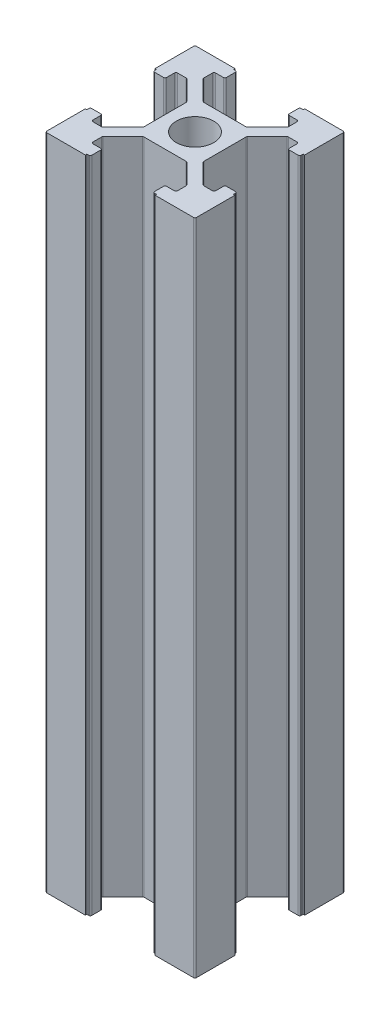
from build123d import *

# Parameters (mm, degrees)
SKETCH1_R           = 2.5
BOSS_EXTRUDE1_DEPTH = 88


with BuildPart() as part:
    # Sketch1 → Boss-Extrude1 (new body)
    with BuildSketch(Plane(origin=(0, 0, 0), x_dir=(1, 0, 0), z_dir=(0, 1, 0))):
        with BuildLine():
            Line((-10, 4.65), (-9.8, 4.65))
            Line((-9.8, 4.65), (-9.8, 4.4))
            ThreePointArc((-9.8, 4.4), (-9.741421356, 4.258578644), (-9.6, 4.2))
            Line((-9.6, 4.2), (-8.4, 4.2))
            ThreePointArc((-8.4, 4.2), (-8.258578644, 4.258578644), (-8.2, 4.4))
            Line((-8.2, 4.4), (-8.2, 5.45))
            ThreePointArc((-8.2, 5.45), (-8.141421356, 5.591421356), (-8, 5.65))
            Line((-8, 5.65), (-6.832842712, 5.65))
            ThreePointArc((-6.832842712, 5.65), (-6.756306026, 5.634775907), (-6.691421356, 5.591421356))
            Line((-6.691421356, 5.591421356), (-4.058578644, 2.958578644))
            ThreePointArc((-4.058578644, 2.958578644), (-4.015224093, 2.893693974), (-4, 2.817157288))
            Line((-4, 2.817157288), (-4, -2.817157288))
            ThreePointArc((-4, -2.817157288), (-4.015224093, -2.893693974), (-4.058578644, -2.958578644))
            Line((-4.058578644, -2.958578644), (-6.691421356, -5.591421356))
            ThreePointArc((-6.691421356, -5.591421356), (-6.756306026, -5.634775907), (-6.832842712, -5.65))
            Line((-6.832842712, -5.65), (-8, -5.65))
            ThreePointArc((-8, -5.65), (-8.141421356, -5.591421356), (-8.2, -5.45))
            Line((-8.2, -5.45), (-8.2, -4.4))
            ThreePointArc((-8.2, -4.4), (-8.258578644, -4.258578644), (-8.4, -4.2))
            Line((-8.4, -4.2), (-9.6, -4.2))
            ThreePointArc((-9.6, -4.2), (-9.741421356, -4.258578644), (-9.8, -4.4))
            Line((-9.8, -4.4), (-9.8, -4.65))
            Line((-9.8, -4.65), (-10, -4.65))
            Line((-10, -4.65), (-10, -9.8))
            ThreePointArc((-10, -9.8), (-9.941421356, -9.941421356), (-9.8, -10))
            Line((-9.8, -10), (-4.65, -10))
            Line((-4.65, -10), (-4.65, -9.8))
            Line((-4.65, -9.8), (-4.4, -9.8))
            ThreePointArc((-4.4, -9.8), (-4.258578644, -9.741421356), (-4.2, -9.6))
            Line((-4.2, -9.6), (-4.2, -8.4))
            ThreePointArc((-4.2, -8.4), (-4.258578644, -8.258578644), (-4.4, -8.2))
            Line((-4.4, -8.2), (-5.45, -8.2))
            ThreePointArc((-5.45, -8.2), (-5.591421356, -8.141421356), (-5.65, -8))
            Line((-5.65, -8), (-5.65, -6.832842712))
            ThreePointArc((-5.65, -6.832842712), (-5.634775907, -6.756306026), (-5.591421356, -6.691421356))
            Line((-5.591421356, -6.691421356), (-2.958578644, -4.058578644))
            ThreePointArc((-2.958578644, -4.058578644), (-2.893693974, -4.015224093), (-2.817157288, -4))
            Line((-2.817157288, -4), (2.817157288, -4))
            ThreePointArc((2.817157288, -4), (2.893693974, -4.015224093), (2.958578644, -4.058578644))
            Line((2.958578644, -4.058578644), (5.591421356, -6.691421356))
            ThreePointArc((5.591421356, -6.691421356), (5.634775907, -6.756306026), (5.65, -6.832842712))
            Line((5.65, -6.832842712), (5.65, -8))
            ThreePointArc((5.65, -8), (5.591421356, -8.141421356), (5.45, -8.2))
            Line((5.45, -8.2), (4.4, -8.2))
            ThreePointArc((4.4, -8.2), (4.258578644, -8.258578644), (4.2, -8.4))
            Line((4.2, -8.4), (4.2, -9.6))
            ThreePointArc((4.2, -9.6), (4.258578644, -9.741421356), (4.4, -9.8))
            Line((4.4, -9.8), (4.65, -9.8))
            Line((4.65, -9.8), (4.65, -10))
            Line((4.65, -10), (9.8, -10))
            ThreePointArc((9.8, -10), (9.941421356, -9.941421356), (10, -9.8))
            Line((10, -9.8), (10, -4.65))
            Line((10, -4.65), (9.8, -4.65))
            Line((9.8, -4.65), (9.8, -4.4))
            ThreePointArc((9.8, -4.4), (9.741421356, -4.258578644), (9.6, -4.2))
            Line((9.6, -4.2), (8.4, -4.2))
            ThreePointArc((8.4, -4.2), (8.258578644, -4.258578644), (8.2, -4.4))
            Line((8.2, -4.4), (8.2, -5.45))
            ThreePointArc((8.2, -5.45), (8.141421356, -5.591421356), (8, -5.65))
            Line((8, -5.65), (6.832842712, -5.65))
            ThreePointArc((6.832842712, -5.65), (6.756306026, -5.634775907), (6.691421356, -5.591421356))
            Line((6.691421356, -5.591421356), (4.058578644, -2.958578644))
            ThreePointArc((4.058578644, -2.958578644), (4.015224093, -2.893693974), (4, -2.817157288))
            Line((4, -2.817157288), (4, 2.817157288))
            ThreePointArc((4, 2.817157288), (4.015224093, 2.893693974), (4.058578644, 2.958578644))
            Line((4.058578644, 2.958578644), (6.691421356, 5.591421356))
            ThreePointArc((6.691421356, 5.591421356), (6.756306026, 5.634775907), (6.832842712, 5.65))
            Line((6.832842712, 5.65), (8, 5.65))
            ThreePointArc((8, 5.65), (8.141421356, 5.591421356), (8.2, 5.45))
            Line((8.2, 5.45), (8.2, 4.4))
            ThreePointArc((8.2, 4.4), (8.258578644, 4.258578644), (8.4, 4.2))
            Line((8.4, 4.2), (9.6, 4.2))
            ThreePointArc((9.6, 4.2), (9.741421356, 4.258578644), (9.8, 4.4))
            Line((9.8, 4.4), (9.8, 4.65))
            Line((9.8, 4.65), (10, 4.65))
            Line((10, 4.65), (10, 9.8))
            ThreePointArc((10, 9.8), (9.941421356, 9.941421356), (9.8, 10))
            Line((9.8, 10), (4.65, 10))
            Line((4.65, 10), (4.65, 9.8))
            Line((4.65, 9.8), (4.4, 9.8))
            ThreePointArc((4.4, 9.8), (4.258578644, 9.741421356), (4.2, 9.6))
            Line((4.2, 9.6), (4.2, 8.4))
            ThreePointArc((4.2, 8.4), (4.258578644, 8.258578644), (4.4, 8.2))
            Line((4.4, 8.2), (5.45, 8.2))
            ThreePointArc((5.45, 8.2), (5.591421356, 8.141421356), (5.65, 8))
            Line((5.65, 8), (5.65, 6.832842712))
            ThreePointArc((5.65, 6.832842712), (5.634775907, 6.756306026), (5.591421356, 6.691421356))
            Line((5.591421356, 6.691421356), (2.958578644, 4.058578644))
            ThreePointArc((2.958578644, 4.058578644), (2.893693974, 4.015224093), (2.817157288, 4))
            Line((2.817157288, 4), (-2.817157288, 4))
            ThreePointArc((-2.817157288, 4), (-2.893693974, 4.015224093), (-2.958578644, 4.058578644))
            Line((-2.958578644, 4.058578644), (-5.591421356, 6.691421356))
            ThreePointArc((-5.591421356, 6.691421356), (-5.634775907, 6.756306026), (-5.65, 6.832842712))
            Line((-5.65, 6.832842712), (-5.65, 8))
            ThreePointArc((-5.65, 8), (-5.591421356, 8.141421356), (-5.45, 8.2))
            Line((-5.45, 8.2), (-4.4, 8.2))
            ThreePointArc((-4.4, 8.2), (-4.258578644, 8.258578644), (-4.2, 8.4))
            Line((-4.2, 8.4), (-4.2, 9.6))
            ThreePointArc((-4.2, 9.6), (-4.258578644, 9.741421356), (-4.4, 9.8))
            Line((-4.4, 9.8), (-4.65, 9.8))
            Line((-4.65, 9.8), (-4.65, 10))
            Line((-4.65, 10), (-9.8, 10))
            ThreePointArc((-9.8, 10), (-9.941421356, 9.941421356), (-10, 9.8))
            Line((-10, 9.8), (-10, 4.65))
        make_face()
        Circle(SKETCH1_R, mode=Mode.SUBTRACT)
    extrude(amount=BOSS_EXTRUDE1_DEPTH)


solid = part.part
